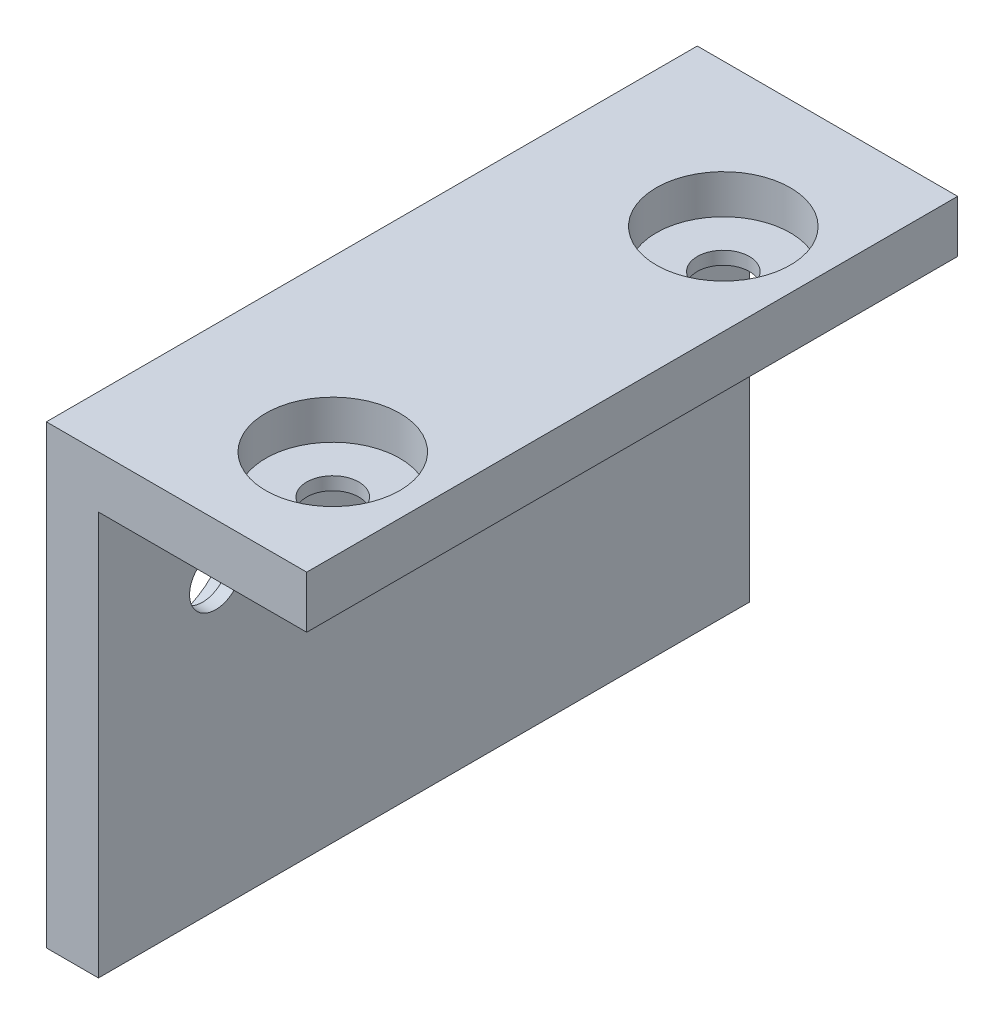
from build123d import *

# Parameters (mm, degrees)
RESSALTO_EXTRUS_O1_DEPTH = 50
ESBO_O2_R                = 5.15
CORTE_EXTRUS_O1_DEPTH    = 3
ESBO_O3_R                = 5.15
CORTE_EXTRUS_O2_DEPTH    = 3
ESBO_O4_R                = 2
CORTE_EXTRUS_O3_DEPTH    = 10
ESBO_O5_R                = 2
CORTE_EXTRUS_O4_DEPTH    = 10


with BuildPart() as part:
    # Esboço1 → Ressalto-extrusão1 (new body)
    with BuildSketch(Plane.XY):
        Polygon((0, 0), (16, 0), (16, 4), (-4, 4), (-4, -31), (0, -31), align=None)
    extrude(amount=RESSALTO_EXTRUS_O1_DEPTH)

    # Esboço2 → Corte-extrusão1 (cut)
    with BuildSketch(Plane(origin=(0, 4, 0), x_dir=(1, 0, 0), z_dir=(0, 1, 0))):
        with Locations((9, -11)):
            Circle(ESBO_O2_R)
        with Locations((9, -41)):
            Circle(ESBO_O2_R)
    extrude(amount=-CORTE_EXTRUS_O1_DEPTH, mode=Mode.SUBTRACT)

    # Esboço3 → Corte-extrusão2 (cut)
    with BuildSketch(Plane.ZY.offset(4)):
        with Locations((11, -9)):
            Circle(ESBO_O3_R)
        with Locations((41, -9)):
            Circle(ESBO_O3_R)
    extrude(amount=-CORTE_EXTRUS_O2_DEPTH, mode=Mode.SUBTRACT)

    # Esboço4 → Corte-extrusão3 (cut)
    with BuildSketch(Plane.ZY.offset(1)):
        with Locations((11, -9)):
            Circle(ESBO_O4_R)
        with Locations((41, -9)):
            Circle(ESBO_O4_R)
    extrude(amount=-CORTE_EXTRUS_O3_DEPTH, mode=Mode.SUBTRACT)

    # Esboço5 → Corte-extrusão4 (cut)
    with BuildSketch(Plane(origin=(0, 1, 0), x_dir=(1, 0, 0), z_dir=(0, 1, 0))):
        with Locations((9, -11)):
            Circle(ESBO_O5_R)
        with Locations((9, -41)):
            Circle(ESBO_O5_R)
    extrude(amount=-CORTE_EXTRUS_O4_DEPTH, mode=Mode.SUBTRACT)


solid = part.part
